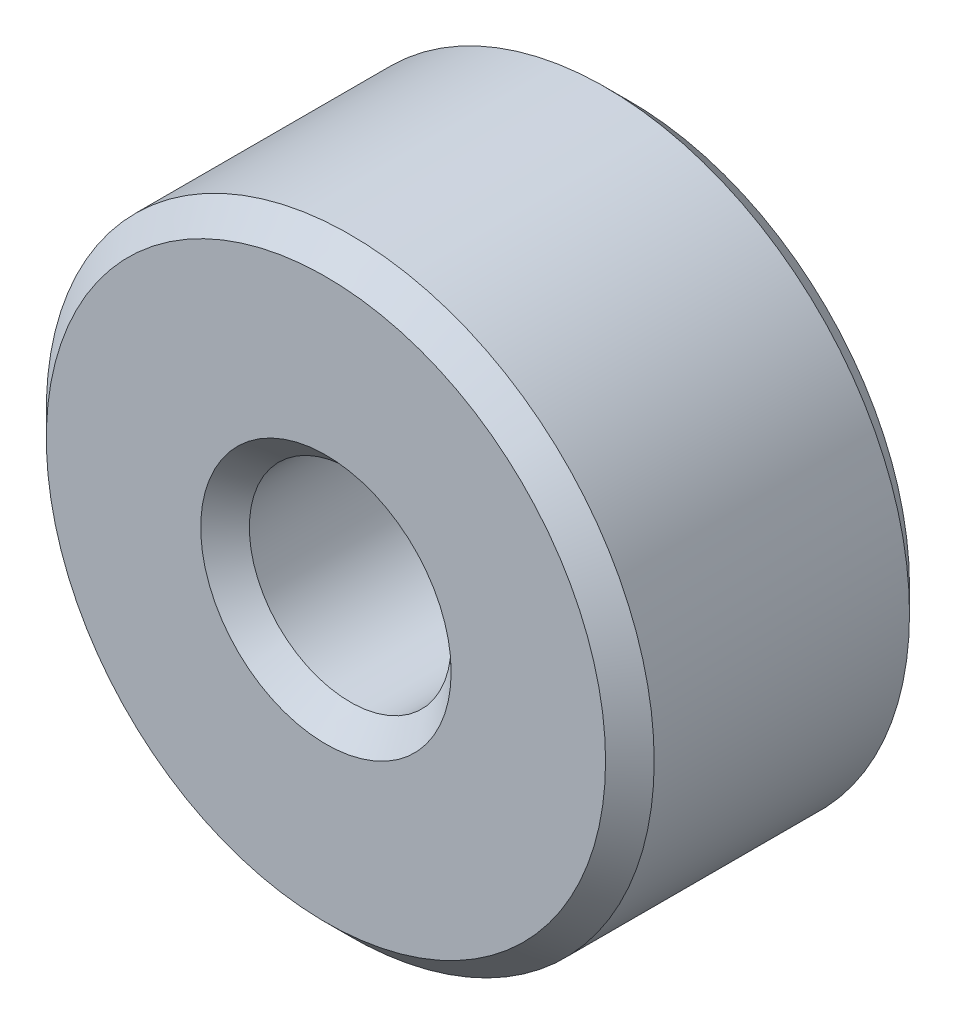
from build123d import *

# Parameters (mm, degrees)
SKETCH3_R                = 6.35
SKETCH3_R_2              = 2.1082
BOSS_EXTRUDE1_DEPTH      = 3.175
BOSS_EXTRUDE1_DEPTH_BACK = 3.175
CHAMFER1_SIZE            = 0.508


with BuildPart() as part:
    # Sketch3 → Boss-Extrude1 (new body, two sides)
    with BuildSketch(Plane.XY) as boss_extrude1_sk:
        Circle(SKETCH3_R)
        Circle(SKETCH3_R_2, mode=Mode.SUBTRACT)
    extrude(amount=BOSS_EXTRUDE1_DEPTH)
    extrude(boss_extrude1_sk.sketch, amount=-BOSS_EXTRUDE1_DEPTH_BACK)

    # Chamfer1
    chamfer1_edges = [part.edges().sort_by_distance(p)[0] for p in [
        (-6.35, 0, -3.175),
        (-2.1082, 0, -3.175),
        (-6.35, 0, 3.175),
        (-2.1082, 0, 3.175),
    ]]
    chamfer(chamfer1_edges, length=CHAMFER1_SIZE)


solid = part.part
